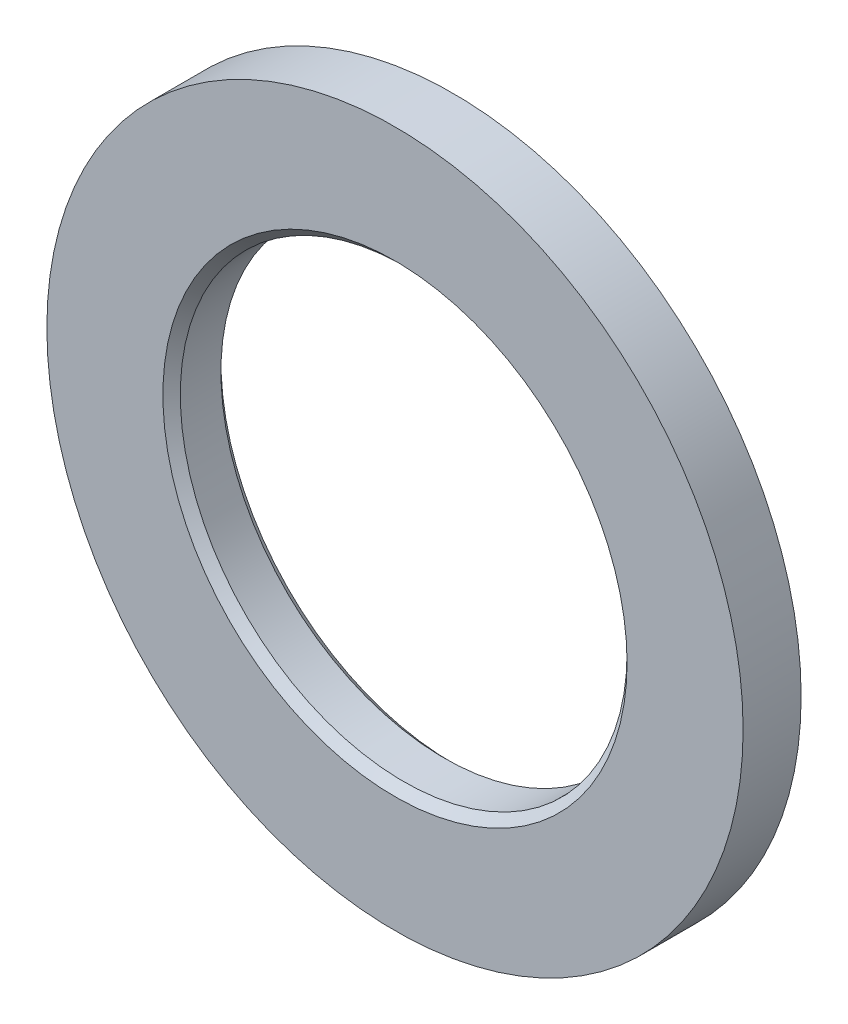
from build123d import *

# Parameters (mm, degrees)
GUARD_BASE_R     = 30
GUARD_DEPTH      = 5
AXLE_HOLE_BASE_R = 19.25
AXLE_HOLE_DEPTH  = 6


with BuildPart() as part:
    # Guard base → Guard (new body)
    with BuildSketch(Plane.XY):
        Circle(GUARD_BASE_R)
    extrude(amount=GUARD_DEPTH)

    # Axle hole base → Axle hole (cut, through all)
    with BuildSketch(Plane.XY.offset(5)):
        Circle(AXLE_HOLE_BASE_R)
    extrude(amount=-AXLE_HOLE_DEPTH, mode=Mode.SUBTRACT)

    # Mate ring room base → Mate ring room (revolve, cut)
    with BuildSketch(Plane(origin=(0, 0, 0), x_dir=(1, 0, 0), z_dir=(0, 1, 0))):
        Polygon((19.25, -5), (20, -5), (19.25, -4.25), align=None)
        Polygon((19.25, 0), (20, 0), (19.25, -0.75), align=None)
    revolve(axis=Axis((0, 0, 0), (0, 0, -1)), mode=Mode.SUBTRACT)


solid = part.part
